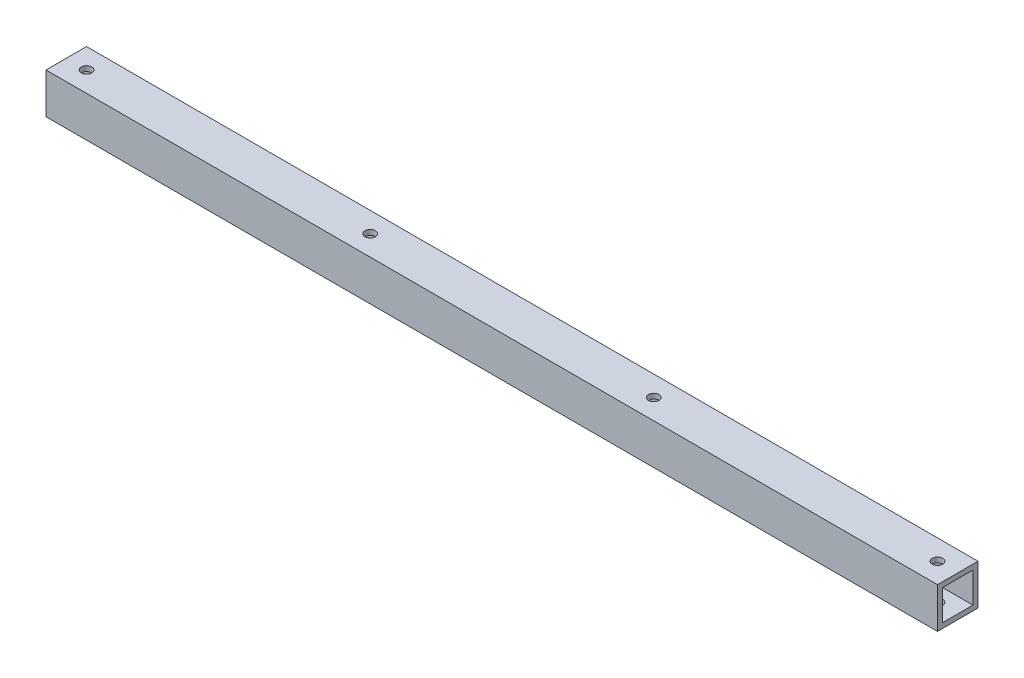
from build123d import *

# Parameters (mm, degrees)
SKETCH1_W          = 25.4
SKETCH1_H          = 25.4
SKETCH1_W_2        = 19.05
SKETCH1_H_2        = 19.05
EXTRUDE1_DEPTH     = 558.8
SKETCH2_R          = 3.2639
CUT_EXTRUDE1_DEPTH = 26.4


with BuildPart() as part:
    # Sketch1 → Extrude1 (new body)
    with BuildSketch(Plane(origin=(0, 0, 0), x_dir=(0, 0, -1), z_dir=(1, 0, 0))):
        with Locations((12.7, 12.7)):
            Rectangle(SKETCH1_W, SKETCH1_H)
        with Locations((12.7, 12.7)):
            Rectangle(SKETCH1_W_2, SKETCH1_H_2, mode=Mode.SUBTRACT)
    extrude(amount=EXTRUDE1_DEPTH)

    # Sketch2 → Cut-Extrude1 (cut, through all)
    with BuildSketch(Plane(origin=(0, 25.4, 0), x_dir=(-1, 0, 0), z_dir=(0, 1, 0))):
        with Locations((-546.1, -12.7)):
            Circle(SKETCH2_R)
        with Locations((-368.3, -12.7)):
            Circle(SKETCH2_R)
        with Locations((-190.5, -12.7)):
            Circle(SKETCH2_R)
        with Locations((-12.7, -12.7)):
            Circle(SKETCH2_R)
    extrude(amount=-CUT_EXTRUDE1_DEPTH, mode=Mode.SUBTRACT)


solid = part.part
